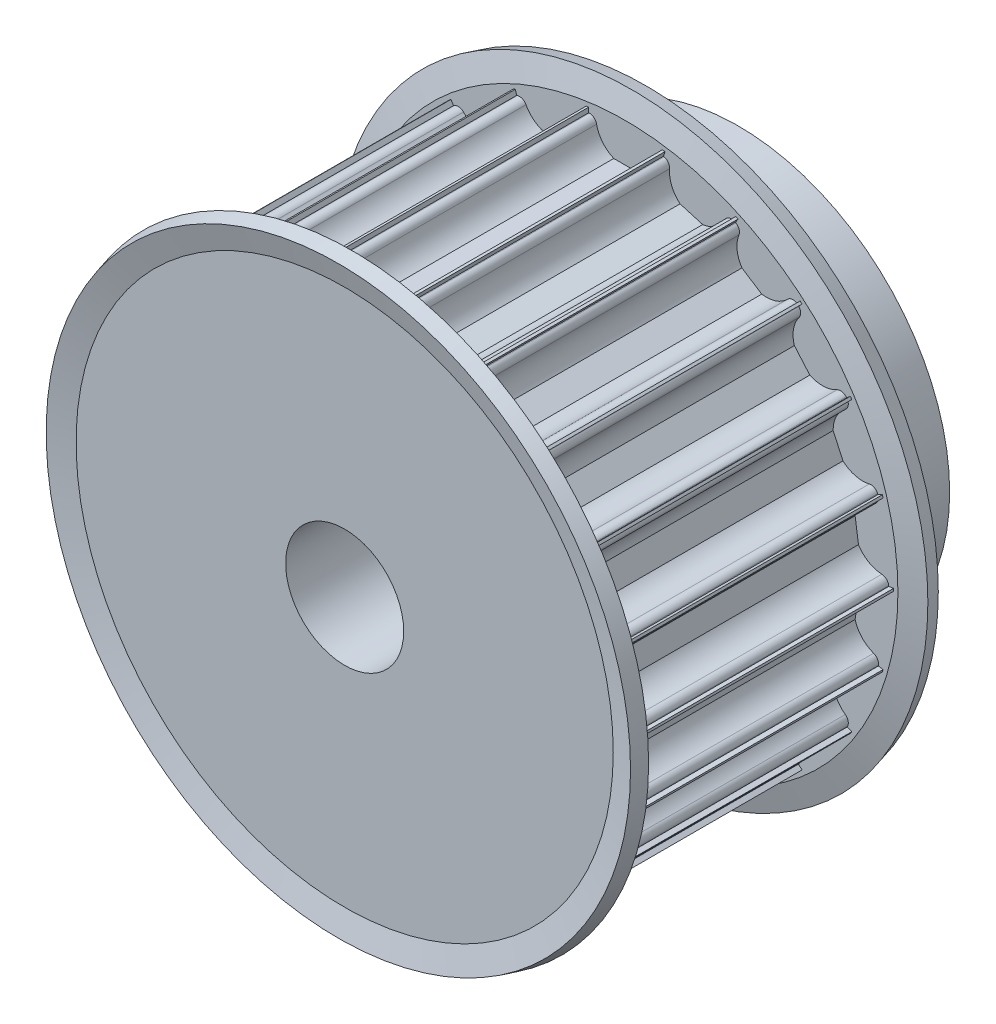
from build123d import *

# Parameters (mm, degrees)
CUT_EXTRUDE1_DEPTH = 41
CIRPATTERN1_COUNT  = 22


with BuildPart() as part:
    # Sketch1 → Revolve1 (revolve)
    with BuildSketch(Plane(origin=(0, 0, 0), x_dir=(0, 0, -1), z_dir=(1, 0, 0))):
        Polygon((0, 6), (0, 27.25), (30, 27.25), (30, 21.5), (40, 21.5), (40, 6), align=None)
    revolve(axis=Axis((0, 0, 59.4), (0, 0, -1)))

    # Sketch2 → Cut-Extrude1 (cut, through all)
    with BuildSketch(Plane.XY):
        with BuildLine():
            Line((1.198957881, 23.75), (-1.198957881, 23.75))
            ThreePointArc((-1.198957881, 23.75), (-2.331759211, 24.612435701), (-2.939387691, 25.9))
            ThreePointArc((-2.939387691, 25.9), (-3.199892965, 26.330947502), (-3.674234614, 26.5))
            Line((-3.674234614, 26.5), (-3.75, 26.5))
            Line((-3.75, 26.5), (-3.75, 28.5))
            Line((-3.75, 28.5), (3.75, 28.5))
            Line((3.75, 28.5), (3.75, 26.5))
            Line((3.75, 26.5), (3.674234614, 26.5))
            ThreePointArc((3.674234614, 26.5), (3.199892965, 26.330947502), (2.939387691, 25.9))
            ThreePointArc((2.939387691, 25.9), (2.331759211, 24.612435701), (1.198957881, 23.75))
        make_face()
    cut_extrude1 = extrude(amount=-CUT_EXTRUDE1_DEPTH, mode=Mode.SUBTRACT)

    # CirPattern1: Cut-Extrude1 ×22 about axis
    cirpattern1_axis = Axis((0, 0, 0), (0, 0, 1))
    for i in range(1, CIRPATTERN1_COUNT):
        add(cut_extrude1.rotate(cirpattern1_axis, i * 360 / CIRPATTERN1_COUNT), mode=Mode.SUBTRACT)

    # Sketch3 → Revolve2 (revolve)
    with BuildSketch(Plane(origin=(0, 0, 0), x_dir=(0, 0, -1), z_dir=(1, 0, 0))):
        Polygon((0, 27.302510585), (0, 22.690739153), (1.448888739, 22.690739153), (1.448888739, 27.690739153), (0.805810678, 30.090739153), (-0.643078062, 29.702510585), align=None)
        Polygon((28.551111261, 22.690739153), (30, 22.690739153), (30, 27.302510585), (30.643078062, 29.702510585), (29.194189322, 30.090739153), (28.551111261, 27.690739153), align=None)
    revolve(axis=Axis((0, 0, 17.206159976), (0, 0, -1)))


solid = part.part
